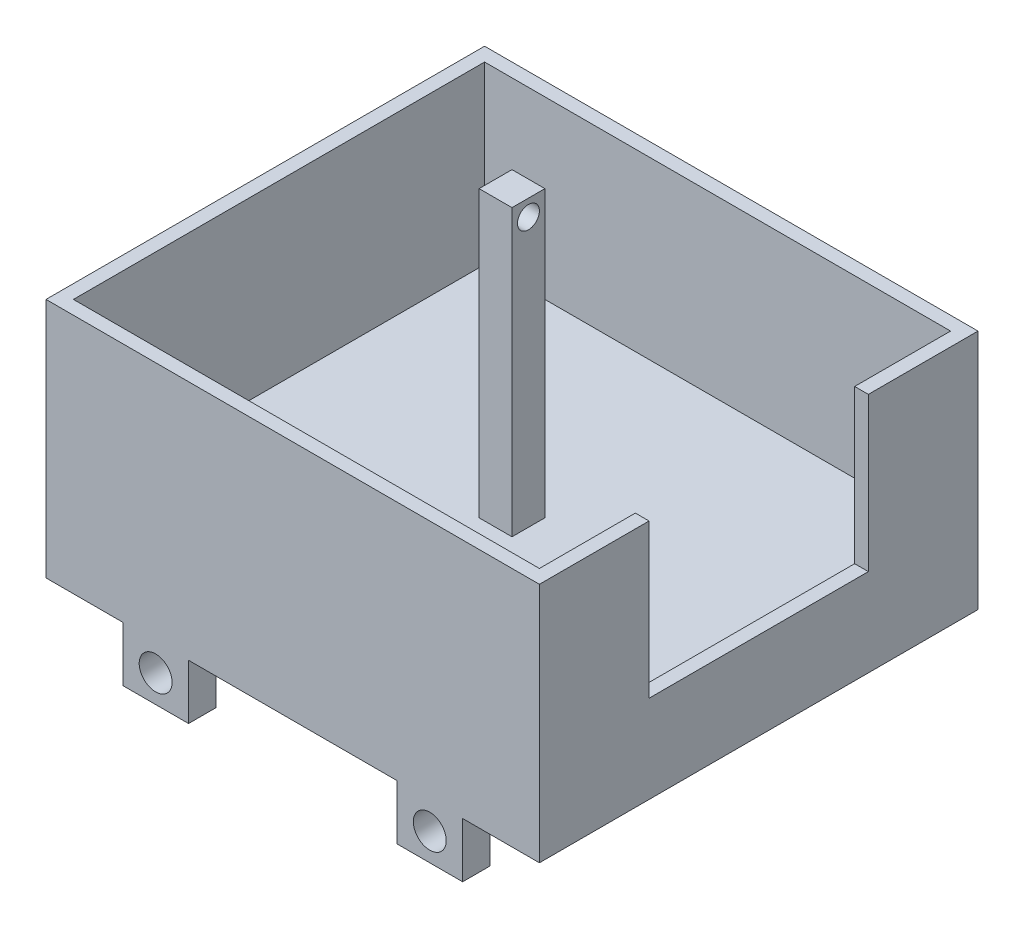
from build123d import *

# Parameters (mm, degrees)
SKETCH1_W           = 450
SKETCH1_H           = 400
BOSS_EXTRUDE1_DEPTH = 220
SKETCH2_W           = 425
SKETCH2_H           = 375
CUT_EXTRUDE1_DEPTH  = 160
SKETCH3_W           = 200
SKETCH3_H           = 140
CUT_EXTRUDE2_DEPTH  = 12.5
SKETCH4_W           = 30
SKETCH4_H           = 30
BOSS_EXTRUDE2_DEPTH = 260
SKETCH5_R           = 10
CUT_EXTRUDE3_DEPTH  = 30
SKETCH6_W           = 60
SKETCH6_H           = 25
BOSS_EXTRUDE3_DEPTH = 50
SKETCH7_R           = 15
CUT_EXTRUDE4_DEPTH  = 25
SKETCH8_R           = 15
CUT_EXTRUDE5_DEPTH  = 25


with BuildPart() as part:
    # Sketch1 → Boss-Extrude1 (new body)
    with BuildSketch(Plane(origin=(0, 0, 0), x_dir=(1, 0, 0), z_dir=(0, 1, 0))):
        Rectangle(SKETCH1_W, SKETCH1_H)
    extrude(amount=BOSS_EXTRUDE1_DEPTH)

    # Sketch2 → Cut-Extrude1 (cut)
    with BuildSketch(Plane(origin=(0, 220, 0), x_dir=(1, 0, 0), z_dir=(0, 1, 0))):
        Rectangle(SKETCH2_W, SKETCH2_H)
    extrude(amount=-CUT_EXTRUDE1_DEPTH, mode=Mode.SUBTRACT)

    # Sketch3 → Cut-Extrude2 (cut)
    with BuildSketch(Plane(origin=(225, 0, 0), x_dir=(0, 0, -1), z_dir=(1, 0, 0))):
        with Locations((0, 150)):
            Rectangle(SKETCH3_W, SKETCH3_H)
    extrude(amount=-CUT_EXTRUDE2_DEPTH, mode=Mode.SUBTRACT)

    # Sketch4 → Boss-Extrude2 (add)
    with BuildSketch(Plane(origin=(0, 60, 0), x_dir=(1, 0, 0), z_dir=(0, 1, 0))):
        Rectangle(SKETCH4_W, SKETCH4_H)
    extrude(amount=BOSS_EXTRUDE2_DEPTH)

    # Sketch5 → Cut-Extrude3 (cut)
    with BuildSketch(Plane(origin=(15, 0, 0), x_dir=(0, 0, -1), z_dir=(1, 0, 0))):
        with Locations((0, 305)):
            Circle(SKETCH5_R)
    extrude(amount=-CUT_EXTRUDE3_DEPTH, mode=Mode.SUBTRACT)

    # Sketch6 → Boss-Extrude3 (add)
    with BuildSketch(Plane.XZ):
        with Locations((125, 187.5)):
            Rectangle(SKETCH6_W, SKETCH6_H)
        with Locations((-125, 187.5)):
            Rectangle(SKETCH6_W, SKETCH6_H)
        with Locations((-125, -187.5)):
            Rectangle(SKETCH6_W, SKETCH6_H)
        with Locations((125, -187.5)):
            Rectangle(SKETCH6_W, SKETCH6_H)
    extrude(amount=BOSS_EXTRUDE3_DEPTH)

    # Sketch7 → Cut-Extrude4 (cut)
    with BuildSketch(Plane(origin=(0, 0, -200), x_dir=(-1, 0, 0), z_dir=(0, 0, -1))):
        with Locations((125, -25)):
            Circle(SKETCH7_R)
        with Locations((-125, -25)):
            Circle(SKETCH7_R)
    extrude(amount=-CUT_EXTRUDE4_DEPTH, mode=Mode.SUBTRACT)

    # Sketch8 → Cut-Extrude5 (cut)
    with BuildSketch(Plane.XY.offset(200)):
        with Locations((-125, -25)):
            Circle(SKETCH8_R)
        with Locations((125, -25)):
            Circle(SKETCH8_R)
    extrude(amount=-CUT_EXTRUDE5_DEPTH, mode=Mode.SUBTRACT)


solid = part.part
